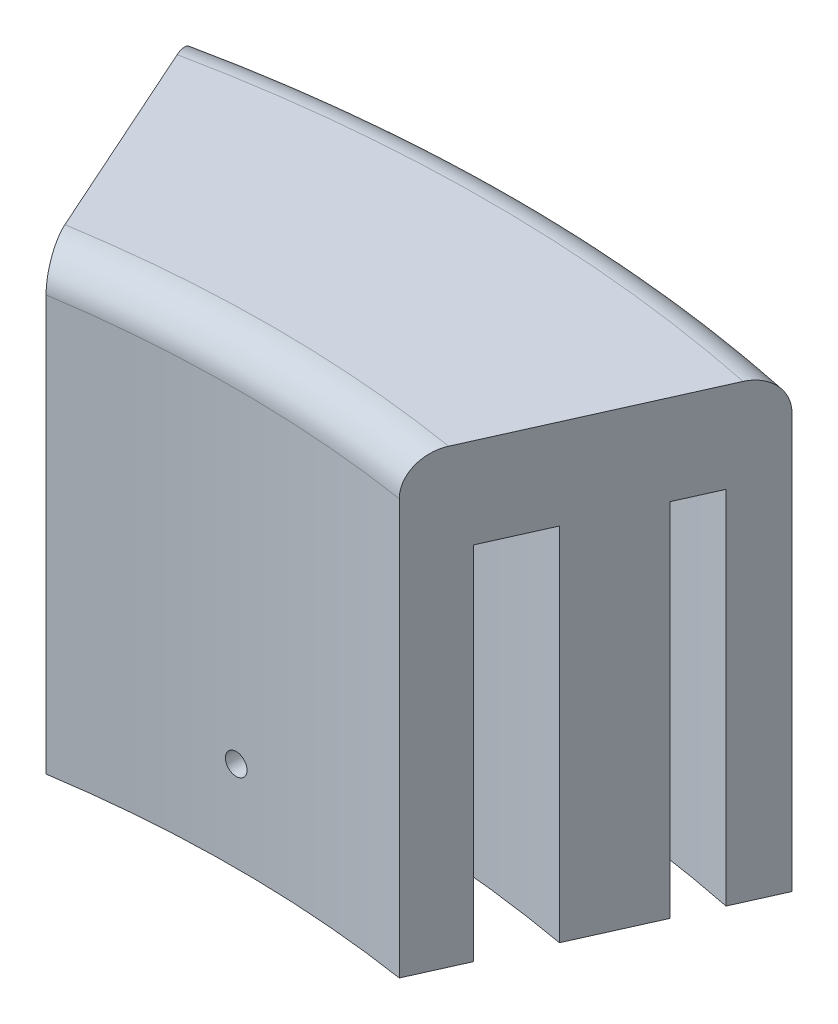
from build123d import *

# Parameters (mm, degrees)
BOSS_EXTRUDE1_DEPTH = 31.75
CUT_EXTRUDE1_DEPTH  = 25.4
FILLET1_R           = 2.54
CUT_EXTRUDE2_DEPTH  = 25.4
SKETCH5_R           = 0.762
CUT_EXTRUDE3_DEPTH  = 266.7


with BuildPart() as part:
    # Sketch1 → Boss-Extrude1 (new body)
    with BuildSketch(Plane(origin=(0, 0, 0), x_dir=(1, 0, 0), z_dir=(0, 1, 0))):
        with BuildLine():
            Line((12.429156122, 80.324059149), (20.977980966, 99.410685113))
            ThreePointArc((20.977980966, 99.410685113), (0, 101.6), (-20.977980966, 99.410685113))
            Line((-20.977980966, 99.410685113), (-12.429156122, 80.324059149))
            ThreePointArc((-12.429156122, 80.324059149), (0, 81.28), (12.429156122, 80.324059149))
        make_face()
    extrude(amount=BOSS_EXTRUDE1_DEPTH)

    # Sketch3 → Cut-Extrude1 (cut)
    with BuildSketch(Plane.XZ):
        with BuildLine():
            Line((-14.041319773, -83.923473707), (-15.916003555, -88.109006667))
            ThreePointArc((-15.916003555, -88.109006667), (0, -89.535), (15.916003555, -88.109006667))
            Line((15.916003555, -88.109006667), (14.041319773, -83.923473707))
            ThreePointArc((14.041319773, -83.923473707), (0, -85.09), (-14.041319773, -83.923473707))
        make_face()
    extrude(amount=-CUT_EXTRUDE1_DEPTH, mode=Mode.SUBTRACT)

    # Fillet1
    fillet1_edges = [part.edges().sort_by_distance(p)[0] for p in [
        (0, 31.75, -81.28),
        (0, 31.75, -101.6),
    ]]
    fillet(fillet1_edges, radius=FILLET1_R)

    # Sketch4 → Cut-Extrude2 (cut)
    with BuildSketch(Plane.XZ):
        with BuildLine():
            Line((-25.786806636, -94.723734325), (-24.259006715, -92.10897401))
            ThreePointArc((-24.259006715, -92.10897401), (10.833808817, -94.63187141), (44.448447191, -84.243088988))
            Line((44.448447191, -84.243088988), (46.527666616, -86.444904305))
            ThreePointArc((46.527666616, -86.444904305), (11.166045621, -97.533915466), (-25.786806636, -94.723734325))
        make_face()
    extrude(amount=-CUT_EXTRUDE2_DEPTH, mode=Mode.SUBTRACT)

    # Sketch5 → Cut-Extrude3 (cut)
    with BuildSketch(Plane.XY):
        with Locations((0, 6.35)):
            Circle(SKETCH5_R)
    extrude(amount=-CUT_EXTRUDE3_DEPTH, mode=Mode.SUBTRACT)


solid = part.part
